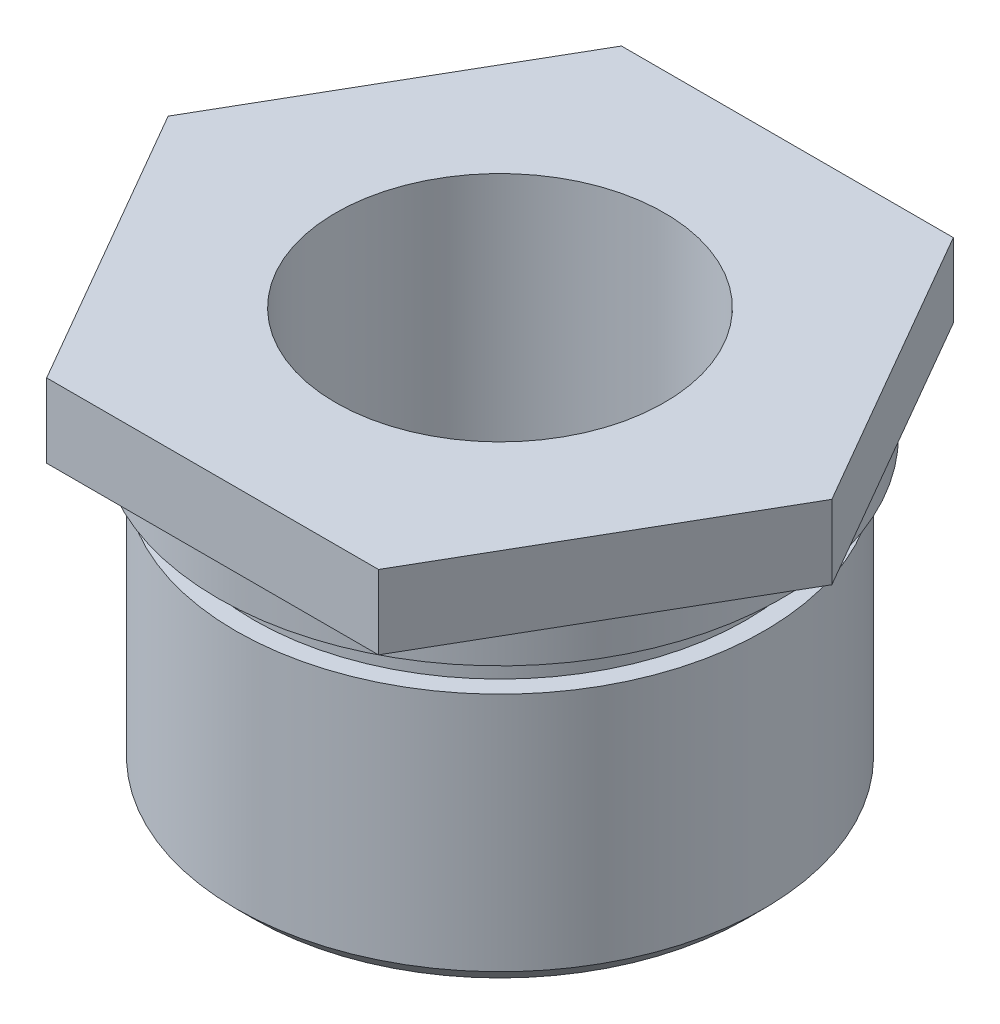
from build123d import *

# Parameters (mm, degrees)
SKETCH2_R           = 7.62
SKETCH2_R_2         = 4.445
BOSS_EXTRUDE1_DEPTH = 2
CHAMFER1_SIZE       = 0.5


with BuildPart() as part:
    # Sketch1 → Revolve1 (revolve)
    with BuildSketch(Plane(origin=(0, 0, 0), x_dir=(0, 0, -1), z_dir=(1, 0, 0)), mode=Mode.PRIVATE) as revolve1_sk:
        Polygon((7.62, 2.5), (7.62, 5.5), (4.445, 5.5), (4.445, -5.5), (7.14375, -5.5), (7.14375, 1.5), (6.64375, 1.5), (6.64375, 2.5), align=None)
    revolve(revolve1_sk.sketch.rotate(Axis((0, 13.854588054, 0), (0, -1, 0)), 180), axis=Axis((0, 13.854588054, 0), (0, -1, 0)))  # turned: the seam where the file's is

    # Sketch2 → Boss-Extrude1 (add)
    with BuildSketch(Plane(origin=(0, 5.5, 0), x_dir=(1, 0, 0), z_dir=(0, 1, 0))):
        Polygon((4.487397232, 7.7724), (-4.487397232, 7.7724), (-8.974794464, 0), (-4.487397232, -7.7724), (4.487397232, -7.7724), (8.974794464, 0), align=None)
        with Locations(Location((0, 0, 0), (0, 0, 270))):  # turned: the seam where the file's is
            Circle(SKETCH2_R, mode=Mode.SUBTRACT)
        with Locations(Location((0, 0, 0), (0, 0, 270))):  # turned: the seam where the file's is
            Circle(SKETCH2_R)
        with Locations(Location((0, 0, 0), (0, 0, 270))):  # turned: the seam where the file's is
            Circle(SKETCH2_R_2, mode=Mode.SUBTRACT)
    extrude(amount=-BOSS_EXTRUDE1_DEPTH)

    # Chamfer1
    chamfer1_edges = [part.edges().sort_by_distance(p)[0] for p in [
        (0, -5.5, -7.14375),
    ]]
    chamfer(chamfer1_edges, length=CHAMFER1_SIZE)


solid = part.part
